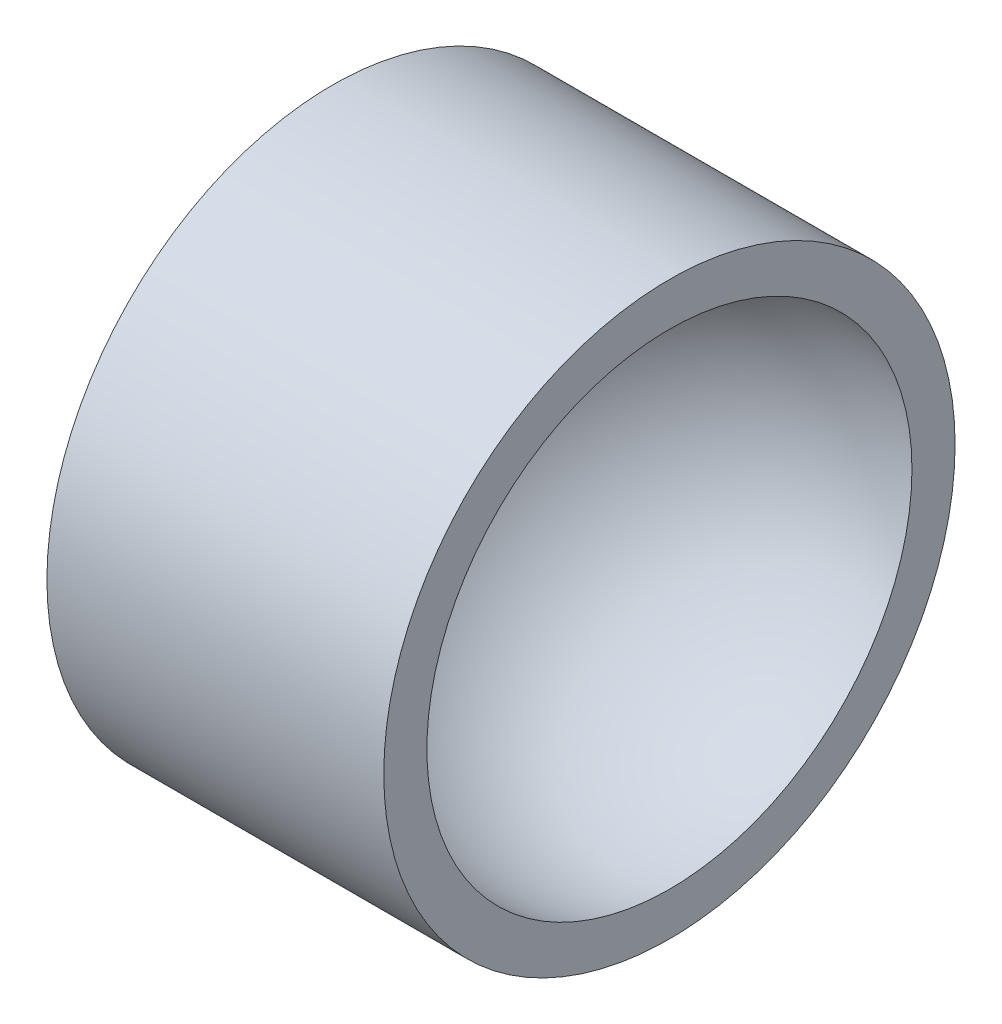
from build123d import *


with BuildPart() as part:
    # Croquis1 → Revolución1 (revolve)
    with BuildSketch(Plane(origin=(0, 0, 0), x_dir=(1, 0, 0), z_dir=(0, 1, 0))):
        with BuildLine():
            Line((-10, 0), (-12.14103606, 0))
            Line((-12.14103606, 0), (-12.14103606, 11.630777084))
            Line((-12.14103606, 11.630777084), (1.574675275, 11.630777084))
            Line((1.574675275, 11.630777084), (1.574675275, 9.875241657))
            ThreePointArc((1.574675275, 9.875241657), (-6.490502571, 7.607455315), (-10, 0))
        make_face()
    revolve(axis=Axis((-10, 0, 0), (-1, 0, 0)))


solid = part.part
